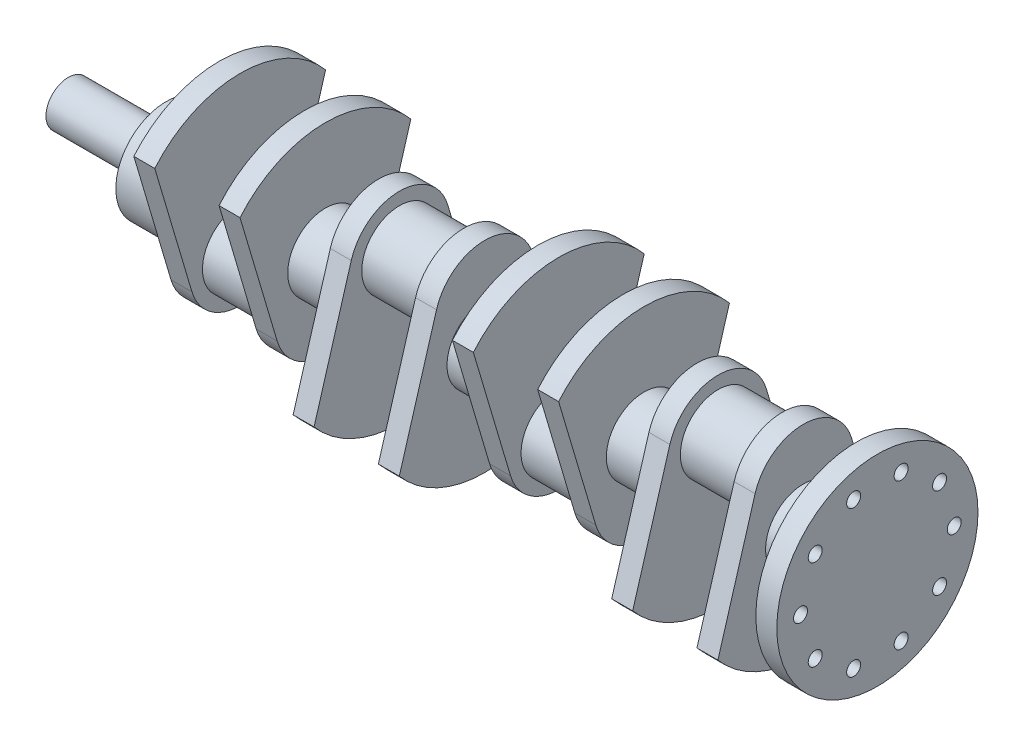
from build123d import *

# Parameters (mm, degrees)
SKETCH1_R            = 16
BOSS_EXTRUDE1_DEPTH  = 70
SKETCH2_R            = 36
BOSS_EXTRUDE2_DEPTH  = 38
BOSS_EXTRUDE3_DEPTH  = 15
SKETCH4_R            = 27
BOSS_EXTRUDE4_DEPTH  = 46
BOSS_EXTRUDE6_DEPTH  = 15
SKETCH9_R            = 27
BOSS_EXTRUDE7_DEPTH  = 38
BOSS_EXTRUDE8_DEPTH  = 15
SKETCH12_R           = 27
BOSS_EXTRUDE9_DEPTH  = 46
BOSS_EXTRUDE10_DEPTH = 15
SKETCH15_R           = 27
BOSS_EXTRUDE11_DEPTH = 38
BOSS_EXTRUDE12_DEPTH = 15
SKETCH17_R           = 27
BOSS_EXTRUDE13_DEPTH = 46
BOSS_EXTRUDE14_DEPTH = 15
SKETCH19_R           = 27
BOSS_EXTRUDE15_DEPTH = 38
BOSS_EXTRUDE16_DEPTH = 15
SKETCH21_R           = 27
BOSS_EXTRUDE17_DEPTH = 46
BOSS_EXTRUDE18_DEPTH = 15
SKETCH23_R           = 27
BOSS_EXTRUDE19_DEPTH = 38
SKETCH24_R           = 72
BOSS_EXTRUDE20_DEPTH = 15
SKETCH25_R           = 5
CUT_EXTRUDE1_DEPTH   = 15


with BuildPart() as part:
    # Sketch1 → Boss-Extrude1 (new body)
    with BuildSketch(Plane(origin=(0, 0, 0), x_dir=(0, 0, -1), z_dir=(1, 0, 0))):
        Circle(SKETCH1_R)
    extrude(amount=BOSS_EXTRUDE1_DEPTH)

    # Sketch2 → Boss-Extrude2 (add)
    with BuildSketch(Plane(origin=(70, 0, 0), x_dir=(0, 0, -1), z_dir=(1, 0, 0))):
        Circle(SKETCH2_R)
    extrude(amount=BOSS_EXTRUDE2_DEPTH)

    # Sketch3 → Boss-Extrude3 (add)
    with BuildSketch(Plane(origin=(108, 0, 0), x_dir=(0, 0, -1), z_dir=(1, 0, 0))):
        with BuildLine():
            Line((34.517510455, -38.224552409), (61.127313745, 51.608637982))
            ThreePointArc((61.127313745, 51.608637982), (0, 80), (-61.127313745, 51.608637982))
            Line((-61.127313745, 51.608637982), (-34.517510455, -38.224552409))
            ThreePointArc((-34.517510455, -38.224552409), (0, -64), (34.517510455, -38.224552409))
        make_face()
    extrude(amount=BOSS_EXTRUDE3_DEPTH)

    # Sketch4 → Boss-Extrude4 (add)
    with BuildSketch(Plane(origin=(123, 0, 0), x_dir=(0, 0, -1), z_dir=(1, 0, 0))):
        with Locations((0, -28)):
            Circle(SKETCH4_R)
    extrude(amount=BOSS_EXTRUDE4_DEPTH)

    # Sketch8 → Boss-Extrude6 (add)
    with BuildSketch(Plane(origin=(169, 0, 0), x_dir=(0, 0, -1), z_dir=(1, 0, 0))):
        with BuildLine():
            Line((34.517510455, -38.224552409), (61.127313745, 51.608637982))
            ThreePointArc((61.127313745, 51.608637982), (0, 80), (-61.127313745, 51.608637982))
            Line((-61.127313745, 51.608637982), (-34.517510455, -38.224552409))
            ThreePointArc((-34.517510455, -38.224552409), (0, -64), (34.517510455, -38.224552409))
        make_face()
    extrude(amount=BOSS_EXTRUDE6_DEPTH)

    # Sketch9 → Boss-Extrude7 (add)
    with BuildSketch(Plane(origin=(184, 0, 0), x_dir=(0, 0, -1), z_dir=(1, 0, 0))):
        Circle(SKETCH9_R)
    extrude(amount=BOSS_EXTRUDE7_DEPTH)


with BuildPart() as body_2:
    # Sketch10 → Boss-Extrude8 (new body)
    with BuildSketch(Plane(origin=(222, 0, 0), x_dir=(0, 0, -1), z_dir=(1, 0, 0))):
        with BuildLine():
            Line((-34.517510455, 38.224552409), (-61.127313745, -51.608637982))
            ThreePointArc((-61.127313745, -51.608637982), (0, -80), (61.127313745, -51.608637982))
            Line((61.127313745, -51.608637982), (34.517510455, 38.224552409))
            ThreePointArc((34.517510455, 38.224552409), (0, 64), (-34.517510455, 38.224552409))
        make_face()
    extrude(amount=BOSS_EXTRUDE8_DEPTH)

    # Sketch12 → Boss-Extrude9 (add)
    with BuildSketch(Plane(origin=(237, 0, 0), x_dir=(0, 0, -1), z_dir=(1, 0, 0))):
        with Locations((0, 28)):
            Circle(SKETCH12_R)
    extrude(amount=BOSS_EXTRUDE9_DEPTH)

    # Sketch13 → Boss-Extrude10 (add)
    with BuildSketch(Plane(origin=(283, 0, 0), x_dir=(0, 0, -1), z_dir=(1, 0, 0))):
        with BuildLine():
            Line((-34.517510455, 38.224552409), (-61.127313745, -51.608637982))
            ThreePointArc((-61.127313745, -51.608637982), (0, -80), (61.127313745, -51.608637982))
            Line((61.127313745, -51.608637982), (34.517510455, 38.224552409))
            ThreePointArc((34.517510455, 38.224552409), (0, 64), (-34.517510455, 38.224552409))
        make_face()
    extrude(amount=BOSS_EXTRUDE10_DEPTH)

    # Sketch15 → Boss-Extrude11 (add)
    with BuildSketch(Plane(origin=(298, 0, 0), x_dir=(0, 0, -1), z_dir=(1, 0, 0))):
        Circle(SKETCH15_R)
    extrude(amount=BOSS_EXTRUDE11_DEPTH)

    # Sketch16 → Boss-Extrude12 (add)
    with BuildSketch(Plane(origin=(336, 0, 0), x_dir=(0, 0, -1), z_dir=(1, 0, 0))):
        with BuildLine():
            Line((34.517510455, -38.224552409), (61.127313745, 51.608637982))
            ThreePointArc((61.127313745, 51.608637982), (0, 80), (-61.127313745, 51.608637982))
            Line((-61.127313745, 51.608637982), (-34.517510455, -38.224552409))
            ThreePointArc((-34.517510455, -38.224552409), (0, -64), (34.517510455, -38.224552409))
        make_face()
    extrude(amount=BOSS_EXTRUDE12_DEPTH)

    # Sketch17 → Boss-Extrude13 (add)
    with BuildSketch(Plane(origin=(351, 0, 0), x_dir=(0, 0, -1), z_dir=(1, 0, 0))):
        with Locations((0, -28)):
            Circle(SKETCH17_R)
    extrude(amount=BOSS_EXTRUDE13_DEPTH)

    # Sketch18 → Boss-Extrude14 (add)
    with BuildSketch(Plane(origin=(397, 0, 0), x_dir=(0, 0, -1), z_dir=(1, 0, 0))):
        with BuildLine():
            Line((-61.127313745, 51.608637982), (-34.517510455, -38.224552409))
            ThreePointArc((-34.517510455, -38.224552409), (0, -64), (34.517510455, -38.224552409))
            Line((34.517510455, -38.224552409), (61.127313745, 51.608637982))
            ThreePointArc((61.127313745, 51.608637982), (0, 80), (-61.127313745, 51.608637982))
        make_face()
    extrude(amount=BOSS_EXTRUDE14_DEPTH)

    # Sketch19 → Boss-Extrude15 (add)
    with BuildSketch(Plane(origin=(412, 0, 0), x_dir=(0, 0, -1), z_dir=(1, 0, 0))):
        Circle(SKETCH19_R)
    extrude(amount=BOSS_EXTRUDE15_DEPTH)

    # Sketch20 → Boss-Extrude16 (add)
    with BuildSketch(Plane(origin=(450, 0, 0), x_dir=(0, 0, -1), z_dir=(1, 0, 0))):
        with BuildLine():
            Line((-34.517510455, 38.224552409), (-61.127313745, -51.608637982))
            ThreePointArc((-61.127313745, -51.608637982), (0, -80), (61.127313745, -51.608637982))
            Line((61.127313745, -51.608637982), (34.517510455, 38.224552409))
            ThreePointArc((34.517510455, 38.224552409), (0, 64), (-34.517510455, 38.224552409))
        make_face()
    extrude(amount=BOSS_EXTRUDE16_DEPTH)

    # Sketch21 → Boss-Extrude17 (add)
    with BuildSketch(Plane(origin=(465, 0, 0), x_dir=(0, 0, -1), z_dir=(1, 0, 0))):
        with Locations((0, 28)):
            Circle(SKETCH21_R)
    extrude(amount=BOSS_EXTRUDE17_DEPTH)

    # Sketch22 → Boss-Extrude18 (add)
    with BuildSketch(Plane(origin=(511, 0, 0), x_dir=(0, 0, -1), z_dir=(1, 0, 0))):
        with BuildLine():
            Line((-34.517510455, 38.224552409), (-61.127313745, -51.608637982))
            ThreePointArc((-61.127313745, -51.608637982), (0, -80), (61.127313745, -51.608637982))
            Line((61.127313745, -51.608637982), (34.517510455, 38.224552409))
            ThreePointArc((34.517510455, 38.224552409), (0, 64), (-34.517510455, 38.224552409))
        make_face()
    extrude(amount=BOSS_EXTRUDE18_DEPTH)

    # Sketch23 → Boss-Extrude19 (add)
    with BuildSketch(Plane(origin=(526, 0, 0), x_dir=(0, 0, -1), z_dir=(1, 0, 0))):
        Circle(SKETCH23_R)
    extrude(amount=BOSS_EXTRUDE19_DEPTH)

    # Sketch24 → Boss-Extrude20 (add)
    with BuildSketch(Plane(origin=(564, 0, 0), x_dir=(0, 0, -1), z_dir=(1, 0, 0))):
        Circle(SKETCH24_R)
    extrude(amount=BOSS_EXTRUDE20_DEPTH)

    # Sketch25 → Cut-Extrude1 (cut)
    with BuildSketch(Plane(origin=(579, 0, 0), x_dir=(0, 0, -1), z_dir=(1, 0, 0))):
        with Locations((55, 0)):
            Circle(SKETCH25_R)
        with Locations((44.495934691, -32.328188876)):
            Circle(SKETCH25_R)
        with Locations((16.995934691, -52.308108396)):
            Circle(SKETCH25_R)
        with Locations((-16.995934691, -52.308108396)):
            Circle(SKETCH25_R)
        with Locations((-44.495934691, -32.328188876)):
            Circle(SKETCH25_R)
        with Locations((-55, 0)):
            Circle(SKETCH25_R)
        with Locations((-44.495934691, 32.328188876)):
            Circle(SKETCH25_R)
        with Locations((-16.995934691, 52.308108396)):
            Circle(SKETCH25_R)
        with Locations((16.995934691, 52.308108396)):
            Circle(SKETCH25_R)
        with Locations((44.495934691, 32.328188876)):
            Circle(SKETCH25_R)
    extrude(amount=-CUT_EXTRUDE1_DEPTH, mode=Mode.SUBTRACT)


solid = Compound([part.part, body_2.part])
